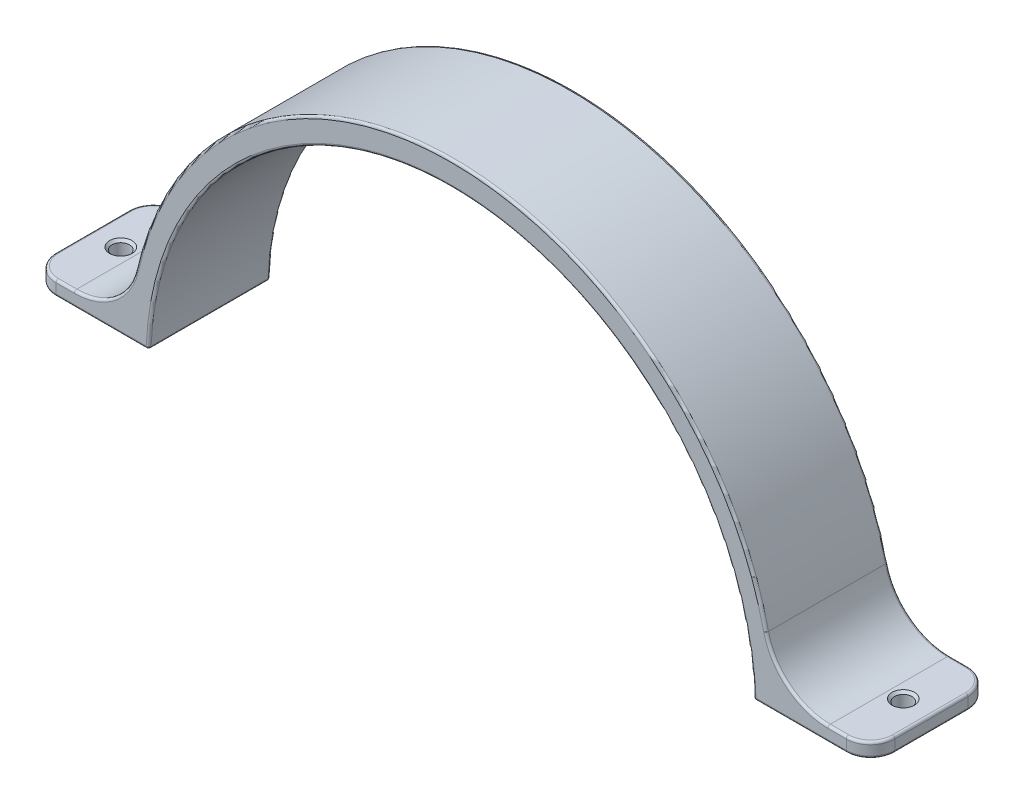
from build123d import *

# Parameters (mm, degrees)
BOSS_EXTRUDE1_DEPTH     = 12.5
SKETCH2_R               = 1.8
CUT_EXTRUDE4_DEPTH      = 36
CUT_EXTRUDE4_DEPTH_BACK = 31
CHAMFER1_SIZE           = 0.5
FILLET1_R               = 13
FILLET2_R               = 5
FILLET3_R               = 0.5


with BuildPart() as part:
    # Sketch1 → Boss-Extrude1 (new body, symmetric)
    with BuildSketch(Plane.XY):
        with BuildLine():
            Line((-86.15, -27), (-66.15, -27))
            ThreePointArc((-66.15, -27), (0, 35), (66.15, -27))
            Line((66.15, -27), (86.15, -27))
            Line((86.15, -27), (86.15, -30))
            Line((86.15, -30), (62.15, -30))
            ThreePointArc((62.15, -30), (0, 30), (-62.15, -30))
            Line((-62.15, -30), (-86.15, -30))
            Line((-86.15, -30), (-86.15, -27))
        make_face()
    extrude(amount=BOSS_EXTRUDE1_DEPTH, both=True)

    # Sketch2 → Cut-Extrude4 (cut, two sides)
    with BuildSketch(Plane(origin=(0, 0, 0), x_dir=(1, 0, 0), z_dir=(0, 1, 0))) as cut_extrude4_sk:
        with Locations((-80.35, 0)):
            Circle(SKETCH2_R)
        with Locations((80.35, 0)):
            Circle(SKETCH2_R)
    extrude(amount=CUT_EXTRUDE4_DEPTH, mode=Mode.SUBTRACT)
    extrude(cut_extrude4_sk.sketch, amount=-CUT_EXTRUDE4_DEPTH_BACK, mode=Mode.SUBTRACT)

    # Chamfer1
    chamfer1_edges = [part.edges().sort_by_distance(p)[0] for p in [
        (-82.15, -27, 0),
        (78.55, -27, 0),
    ]]
    chamfer(chamfer1_edges, length=CHAMFER1_SIZE)

    # Fillet1
    fillet1_edges = [part.edges().sort_by_distance(p)[0] for p in [
        (66.15, -27, 0),
        (-66.15, -27, 0),
    ]]
    fillet(fillet1_edges, radius=FILLET1_R)

    # Fillet2
    fillet2_edges = [part.edges().sort_by_distance(p)[0] for p in [
        (-86.15, -28.5, -12.5),
        (-86.15, -28.5, 12.5),
        (86.15, -28.5, 12.5),
        (86.15, -28.5, -12.5),
    ]]
    fillet(fillet2_edges, radius=FILLET2_R)

    # Fillet3
    fillet3_edges = [part.edges().sort_by_distance(p)[0] for p in [
        (62.15, -30, 0),
        (-62.15, -30, 0),
        (0, 30, 12.5),
        (71.65, -30, 12.5),
        (0, 35, -12.5),
        (0, 35, 12.5),
        (-79.265510788, -27, -12.5),
        (-79.265510788, -27, 12.5),
        (69.252379009, -24.145204287, -12.5),
        (69.252379009, -24.145204287, 12.5),
        (-69.252379009, -24.145204287, -12.5),
        (-69.252379009, -24.145204287, 12.5),
        (79.265510788, -27, 12.5),
        (-71.65, -30, 12.5),
        (79.265510788, -27, -12.5),
        (86.15, -27, 0),
        (84.685533906, -27, -11.035533906),
        (84.685533906, -27, 11.035533906),
        (86.15, -30, 0),
        (84.685533906, -30, -11.035533906),
        (84.685533906, -30, 11.035533906),
        (-71.65, -30, -12.5),
        (-86.15, -30, 0),
        (-86.15, -27, 0),
        (-84.685533906, -30, 11.035533906),
        (-84.685533906, -30, -11.035533906),
        (-84.685533906, -27, 11.035533906),
        (-84.685533906, -27, -11.035533906),
        (71.65, -30, -12.5),
        (0, 30, -12.5),
    ]]
    fillet(fillet3_edges, radius=FILLET3_R)


solid = part.part
